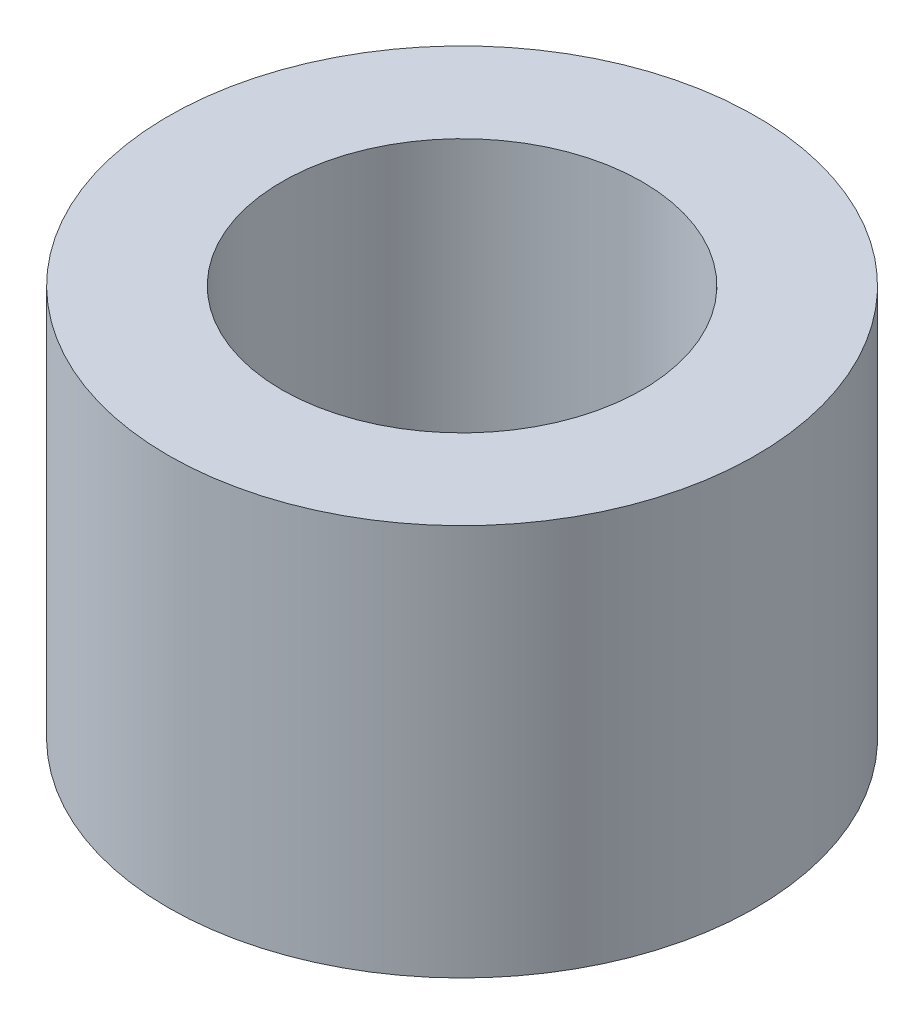
from build123d import *

# Parameters (mm, degrees)
SKETCH1_R           = 2.38125
SKETCH1_R_2         = 1.4605
BOSS_EXTRUDE1_DEPTH = 3.175


with BuildPart() as part:
    # Sketch1 → Boss-Extrude1 (new body)
    with BuildSketch(Plane(origin=(0, 0, 0), x_dir=(1, 0, 0), z_dir=(0, 1, 0))):
        Circle(SKETCH1_R)
        Circle(SKETCH1_R_2, mode=Mode.SUBTRACT)
    extrude(amount=BOSS_EXTRUDE1_DEPTH)


solid = part.part
